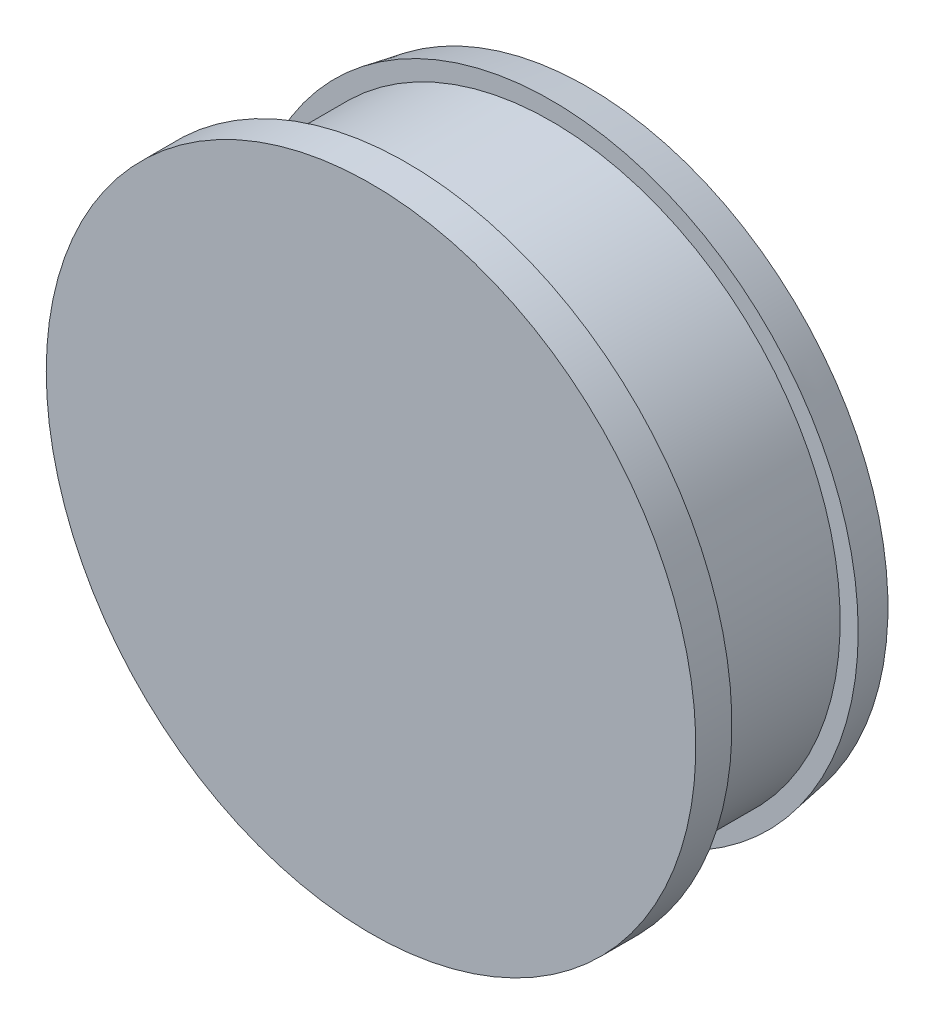
from build123d import *


with BuildPart() as part:
    # Sketch1 → Revolve1 (revolve)
    with BuildSketch(Plane(origin=(0, 0, 0), x_dir=(0, 0, -1), z_dir=(1, 0, 0))):
        Polygon((0, 0), (0, 28.575), (3.175, 28.575), (3.175, 25.4), (15.875, 25.4), (15.875, 26.9875), (19.05, 26.427661836), (19.05, 0), align=None)
    revolve(axis=Axis((0, 0, 6.675085324), (0, 0, 1)))


solid = part.part
